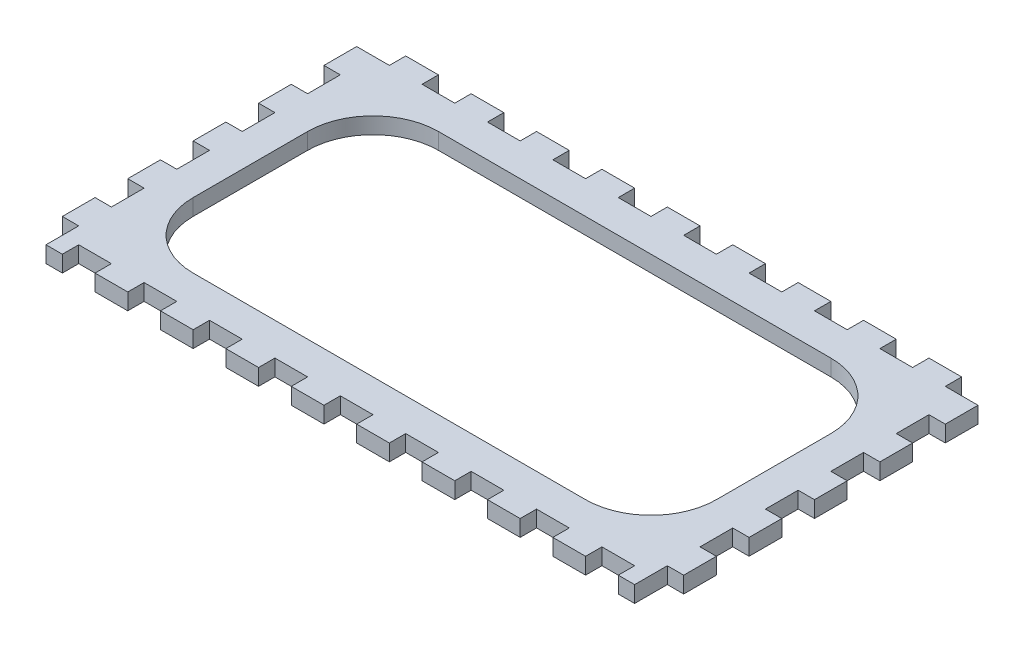
from build123d import *

# Parameters (mm, degrees)
SKETCH2_W           = 241.3
SKETCH2_H           = 133.35
BOSS_EXTRUDE1_DEPTH = 6.35
SKETCH3_W           = 6.35
SKETCH3_H           = 12.7
CUT_EXTRUDE1_DEPTH  = 7.35
LPATTERN1_COUNT     = 6
LPATTERN1_PITCH     = 25.4
SKETCH4_W           = 12.7
SKETCH4_H           = 6.35
CUT_EXTRUDE2_DEPTH  = 7.35
LPATTERN2_COUNT     = 10
LPATTERN2_PITCH     = 25.4
SKETCH5_W           = 12.7
SKETCH5_H           = 6.35
CUT_EXTRUDE3_DEPTH  = 7.35
LPATTERN3_COUNT     = 10
LPATTERN3_PITCH     = 25.4
SKETCH6_W           = 203.2
SKETCH6_H           = 95.25
CUT_EXTRUDE4_DEPTH  = 7.35
FILLET1_R           = 25.4


with BuildPart() as part:
    # Sketch2 → Boss-Extrude1 (new body)
    with BuildSketch(Plane(origin=(0, 0, 0), x_dir=(1, 0, 0), z_dir=(0, 1, 0))):
        with Locations((120.65, 66.675)):
            Rectangle(SKETCH2_W, SKETCH2_H)
    extrude(amount=BOSS_EXTRUDE1_DEPTH)

    # Sketch3 → Cut-Extrude1 (cut, through all)
    with BuildSketch(Plane(origin=(0, 6.35, 0), x_dir=(1, 0, 0), z_dir=(0, 1, 0))):
        with Locations((3.175, 6.35)):
            Rectangle(SKETCH3_W, SKETCH3_H)
        with Locations((238.125, 6.35)):
            Rectangle(SKETCH3_W, SKETCH3_H)
    cut_extrude1 = extrude(amount=-CUT_EXTRUDE1_DEPTH, mode=Mode.SUBTRACT)

    # LPattern1: Cut-Extrude1 ×6
    with Locations(*[(0, 0, -i * LPATTERN1_PITCH) for i in range(1, LPATTERN1_COUNT)]):
        add(cut_extrude1, mode=Mode.SUBTRACT)

    # Sketch4 → Cut-Extrude2 (cut, through all)
    with BuildSketch(Plane(origin=(0, 6.35, 0), x_dir=(1, 0, 0), z_dir=(0, 1, 0))):
        with Locations((222.25, 3.175)):
            Rectangle(SKETCH4_W, SKETCH4_H)
    cut_extrude2 = extrude(amount=-CUT_EXTRUDE2_DEPTH, mode=Mode.SUBTRACT)

    # LPattern2: Cut-Extrude2 ×10
    with Locations(*[(-i * LPATTERN2_PITCH, 0, 0) for i in range(1, LPATTERN2_COUNT)]):
        add(cut_extrude2, mode=Mode.SUBTRACT)

    # Sketch5 → Cut-Extrude3 (cut, through all)
    with BuildSketch(Plane(origin=(0, 6.35, 0), x_dir=(1, 0, 0), z_dir=(0, 1, 0))):
        with Locations((6.35, 130.175)):
            Rectangle(SKETCH5_W, SKETCH5_H)
    cut_extrude3 = extrude(amount=-CUT_EXTRUDE3_DEPTH, mode=Mode.SUBTRACT)

    # LPattern3: Cut-Extrude3 ×10
    with Locations(*[(i * LPATTERN3_PITCH, 0, 0) for i in range(1, LPATTERN3_COUNT)]):
        add(cut_extrude3, mode=Mode.SUBTRACT)

    # Sketch6 → Cut-Extrude4 (cut, through all)
    with BuildSketch(Plane(origin=(0, 6.35, 0), x_dir=(1, 0, 0), z_dir=(0, 1, 0))):
        with Locations((120.65, 66.675)):
            Rectangle(SKETCH6_W, SKETCH6_H)
    extrude(amount=-CUT_EXTRUDE4_DEPTH, mode=Mode.SUBTRACT)

    # Fillet1
    fillet1_edges = [part.edges().sort_by_distance(p)[0] for p in [
        (19.05, 3.175, -19.05),
        (19.05, 3.175, -114.3),
        (222.25, 3.175, -114.3),
        (222.25, 3.175, -19.05),
    ]]
    fillet(fillet1_edges, radius=FILLET1_R)


solid = part.part
